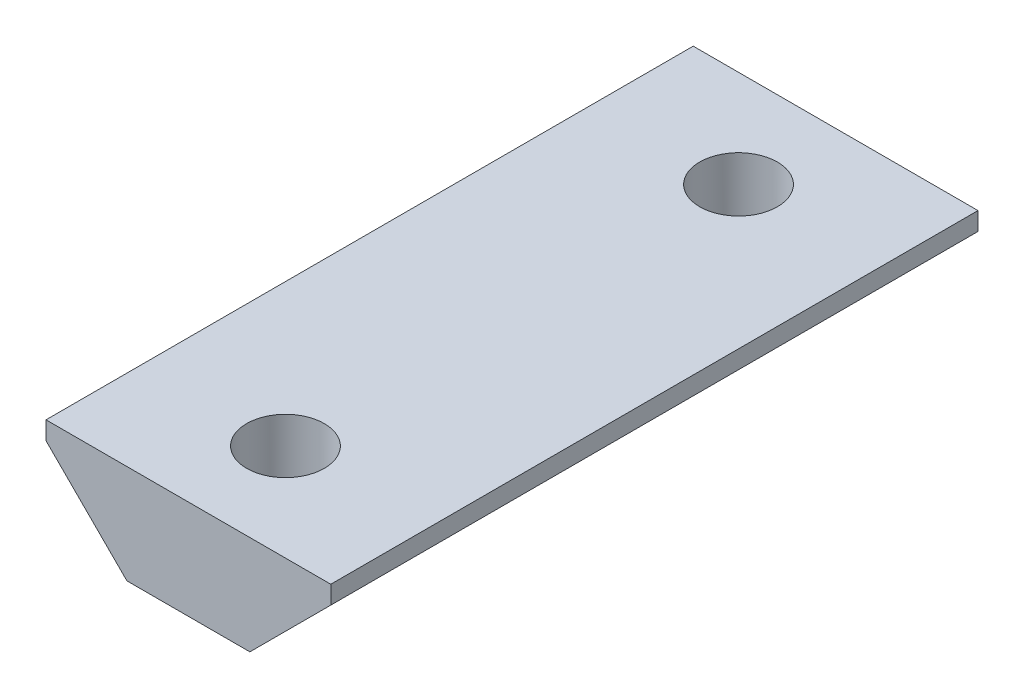
from build123d import *

# Parameters (mm, degrees)
BOSS_EXTRUDE1_DEPTH = 25
SKETCH2_R           = 3
CUT_EXTRUDE1_DEPTH  = 25


with BuildPart() as part:
    # Sketch1 → Boss-Extrude1 (new body, symmetric)
    with BuildSketch(Plane.XY):
        Polygon((4.75, 0), (-4.75, 0), (-11, 6.25), (-11, 7.65), (11, 7.65), (11, 6.25), align=None)
    extrude(amount=BOSS_EXTRUDE1_DEPTH, both=True)

    # Sketch2 → Cut-Extrude1 (cut, symmetric)
    with BuildSketch(Plane(origin=(0, 7.65, 0), x_dir=(1, 0, 0), z_dir=(0, 1, 0))):
        with Locations((0, 17.5)):
            Circle(SKETCH2_R)
        with Locations((0, -17.5)):
            Circle(SKETCH2_R)
    extrude(amount=CUT_EXTRUDE1_DEPTH, both=True, mode=Mode.SUBTRACT)


solid = part.part
